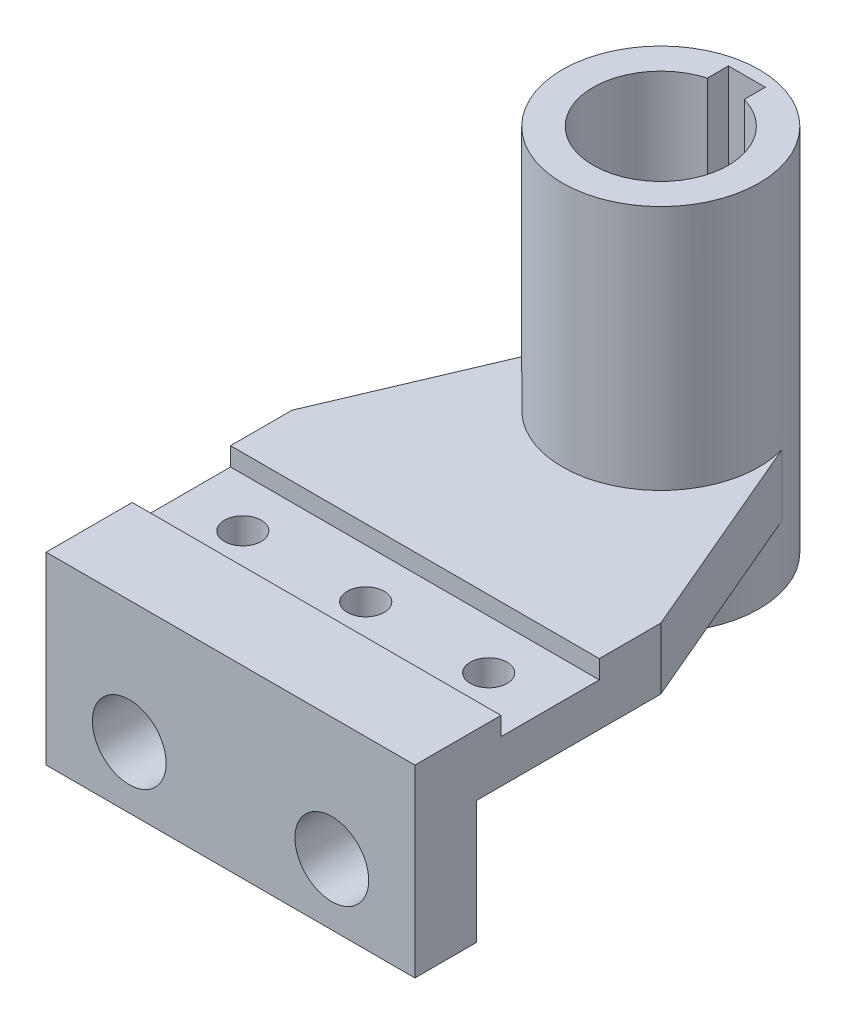
from build123d import *

# Parameters (mm, degrees)
BOSS_EXTRUDE1_DEPTH      = 10
BOSS_EXTRUDE2_DEPTH      = 40
BOSS_EXTRUDE2_DEPTH_BACK = 20
CUT_EXTRUDE1_DEPTH       = 61
SKETCH5_W                = 60
SKETCH5_H                = 10
BOSS_EXTRUDE3_DEPTH      = 20
CUT_EXTRUDE2_REACH       = 88
SKETCH6_R                = 6
SKETCH9_W                = 60
SKETCH9_H                = 16
SKETCH9_R                = 3
CUT_EXTRUDE4_DEPTH       = 3
SKETCH10_R               = 3
CUT_EXTRUDE5_DEPTH       = 38


with BuildPart() as part:
    # Sketch1 → Boss-Extrude1 (new body)
    with BuildSketch(Plane(origin=(0, 0, 0), x_dir=(1, 0, 0), z_dir=(0, 1, 0))):
        with BuildLine():
            Line((-30, 0), (-15.411351, 34.300029))
            ThreePointArc((-15.411351, 34.300029), (0, 46), (15.411351, 34.300029))
            Line((15.411351, 34.300029), (30, 0))
            Line((30, 0), (30, -40))
            Line((30, -40), (-30, -40))
            Line((-30, -40), (-30, 0))
        make_face()
    extrude(amount=BOSS_EXTRUDE1_DEPTH)

    # Sketch2 → Boss-Extrude2 (add, two sides)
    with BuildSketch(Plane(origin=(0, 10, 0), x_dir=(1, 0, 0), z_dir=(0, 1, 0))) as boss_extrude2_sk:
        with BuildLine():
            ThreePointArc((15.411351, 34.300029), (0, 46), (-15.411351, 34.300029))
            ThreePointArc((-15.411351, 34.300029), (-2.170066, 14.147845), (16, 30))
            ThreePointArc((16, 30), (15.852155, 32.170066), (15.411351, 34.300029))
        make_face()
    extrude(amount=BOSS_EXTRUDE2_DEPTH)
    extrude(boss_extrude2_sk.sketch, amount=-BOSS_EXTRUDE2_DEPTH_BACK)

    # Sketch3 → Cut-Extrude1 (cut, through all)
    with BuildSketch(Plane(origin=(0, 50, 0), x_dir=(1, 0, 0), z_dir=(0, 1, 0))):
        with BuildLine():
            Line((-3, 44), (3, 44))
            Line((3, 44), (3, 40.583005))
            ThreePointArc((3, 40.583005), (0, 19), (-3, 40.583005))
            Line((-3, 40.583005), (-3, 44))
        make_face()
    extrude(amount=-CUT_EXTRUDE1_DEPTH, mode=Mode.SUBTRACT)

    # Sketch5 → Boss-Extrude3 (add)
    with BuildSketch(Plane(origin=(0, 0, 0), x_dir=(-1, 0, 0), z_dir=(0, -1, 0))):
        with Locations((0, -35)):
            Rectangle(SKETCH5_W, SKETCH5_H)
    extrude(amount=BOSS_EXTRUDE3_DEPTH)

    # Sketch6 → Cut-Extrude2 (cut, up to next)
    with BuildSketch(Plane.XY.offset(40), mode=Mode.PRIVATE) as cut_extrude2_sk1:
        with Locations((16.477302, -10)):
            Circle(SKETCH6_R)
    cut_extrude2_tool1 = extrude(cut_extrude2_sk1.sketch, amount=-CUT_EXTRUDE2_REACH, mode=Mode.PRIVATE) & part.part
    add(cut_extrude2_tool1.solids().sort_by_distance((16.477302, -10, 40))[0], mode=Mode.SUBTRACT)
    # Sketch6 → Cut-Extrude2 (cut, up to next)
    with BuildSketch(Plane.XY.offset(40), mode=Mode.PRIVATE) as cut_extrude2_sk2:
        with Locations((-16.477302, -10)):
            Circle(SKETCH6_R)
    cut_extrude2_tool2 = extrude(cut_extrude2_sk2.sketch, amount=-CUT_EXTRUDE2_REACH, mode=Mode.PRIVATE) & part.part
    add(cut_extrude2_tool2.solids().sort_by_distance((-16.477302, -10, 40))[0], mode=Mode.SUBTRACT)

    # Sketch9 → Cut-Extrude4 (cut)
    with BuildSketch(Plane(origin=(0, 10, 0), x_dir=(1, 0, 0), z_dir=(0, 1, 0))):
        with Locations((0, -18)):
            Rectangle(SKETCH9_W, SKETCH9_H)
        with Locations((0, -18)):
            Circle(SKETCH9_R, mode=Mode.SUBTRACT)
        with Locations((20, -18)):
            Circle(SKETCH9_R, mode=Mode.SUBTRACT)
        with Locations((-20, -18)):
            Circle(SKETCH9_R, mode=Mode.SUBTRACT)
    extrude(amount=-CUT_EXTRUDE4_DEPTH, mode=Mode.SUBTRACT)

    # Sketch10 → Cut-Extrude5 (cut, through all)
    with BuildSketch(Plane(origin=(0, 17, 0), x_dir=(1, 0, 0), z_dir=(0, 1, 0))):
        with Locations((20, -18)):
            Circle(SKETCH10_R)
        with Locations((0, -18)):
            Circle(SKETCH10_R)
        with Locations((-20, -18)):
            Circle(SKETCH10_R)
    extrude(amount=-CUT_EXTRUDE5_DEPTH, mode=Mode.SUBTRACT)


solid = part.part
